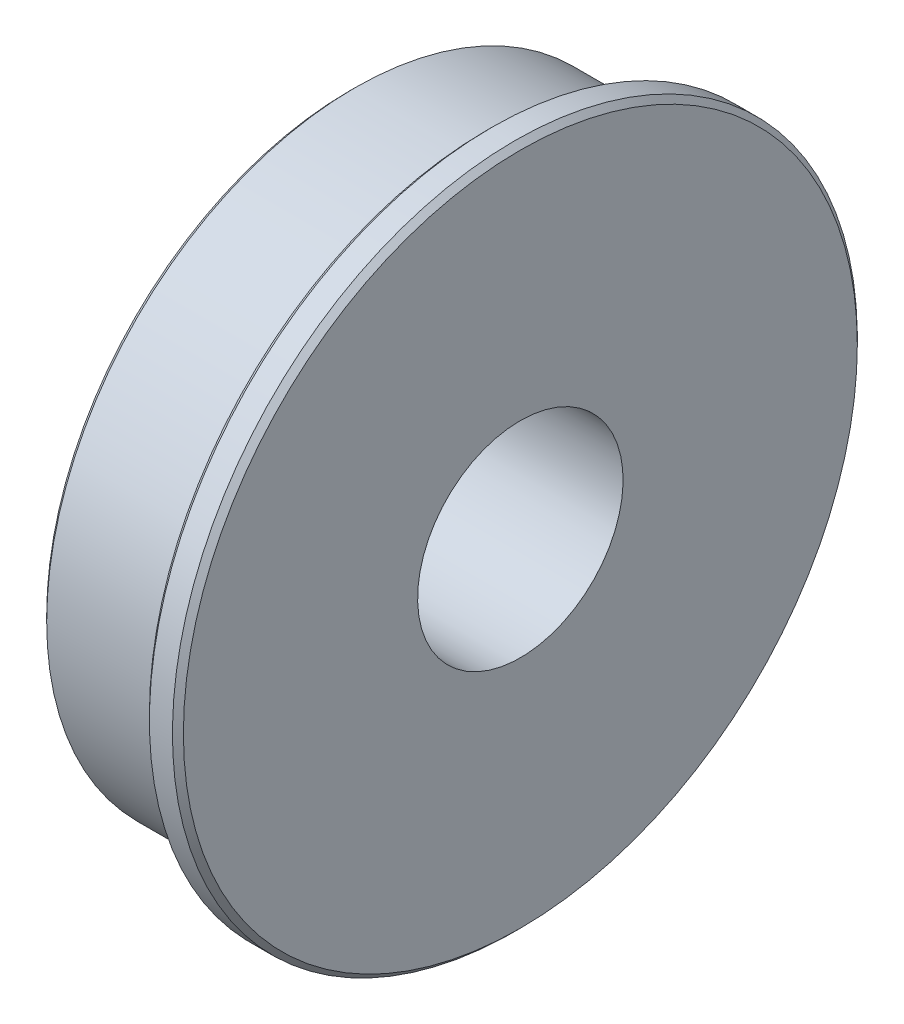
from build123d import *

# Parameters (mm, degrees)
CHAMFER1_SIZE = 0.254


with BuildPart() as part:
    # Sketch1 → Revolve1 (revolve)
    with BuildSketch(Plane.XY):
        Polygon((-3.9624, 14.2875), (2.3876, 14.2875), (2.3876, 15.875), (3.9624, 15.875), (3.9624, 4.7625), (-3.9624, 4.7625), align=None)
    revolve(axis=Axis((3.9624, 0, 0), (-1, 0, 0)))

    # Chamfer1
    chamfer1_edges = [part.edges().sort_by_distance(p)[0] for p in [
        (3.9624, -15.875, 0),
        (2.3876, -15.875, 0),
        (-3.9624, -14.2875, 0),
    ]]
    chamfer(chamfer1_edges, length=CHAMFER1_SIZE)


solid = part.part
